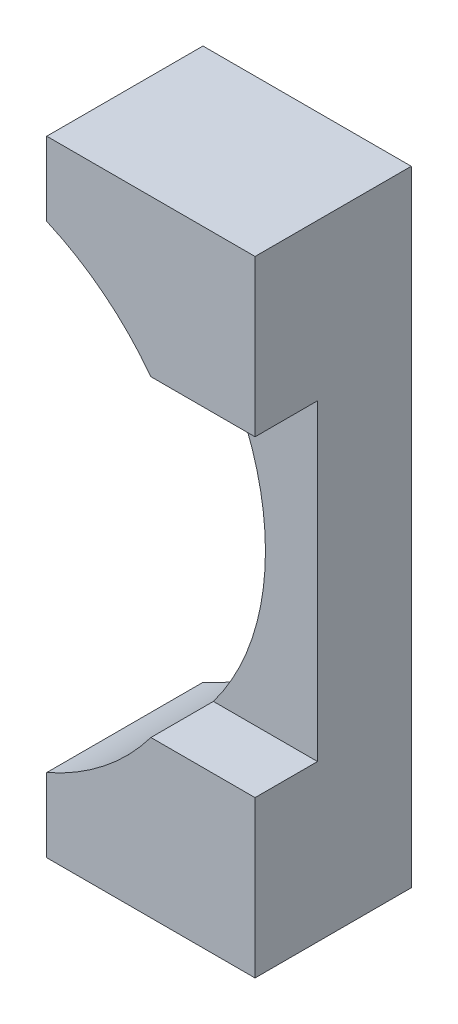
from build123d import *

# Parameters (mm, degrees)
SKETCH1_W           = 25.4
SKETCH1_H           = 76.2
BOSS_EXTRUDE1_DEPTH = 19.05
SKETCH2_R           = 31.75
CUT_EXTRUDE1_DEPTH  = 25.4
SKETCH4_W           = 7.62
SKETCH4_H           = 38.1
CUT_EXTRUDE3_DEPTH  = 83.55


with BuildPart() as part:
    # Sketch1 → Boss-Extrude1 (new body)
    with BuildSketch(Plane.XY):
        with Locations((12.7, 38.1)):
            Rectangle(SKETCH1_W, SKETCH1_H)
    extrude(amount=BOSS_EXTRUDE1_DEPTH)

    # Sketch2 → Cut-Extrude1 (cut)
    with BuildSketch(Plane.XY.offset(19.05)):
        with Locations((-12.7, 38.1)):
            Circle(SKETCH2_R)
    extrude(amount=-CUT_EXTRUDE1_DEPTH, mode=Mode.SUBTRACT)

    # Sketch4 → Cut-Extrude3 (cut, through all)
    with BuildSketch(Plane(origin=(25.4, 0, 0), x_dir=(0, 0, -1), z_dir=(1, 0, 0))):
        with Locations((-15.24, 38.1)):
            Rectangle(SKETCH4_W, SKETCH4_H)
    extrude(amount=-CUT_EXTRUDE3_DEPTH, mode=Mode.SUBTRACT)


solid = part.part
